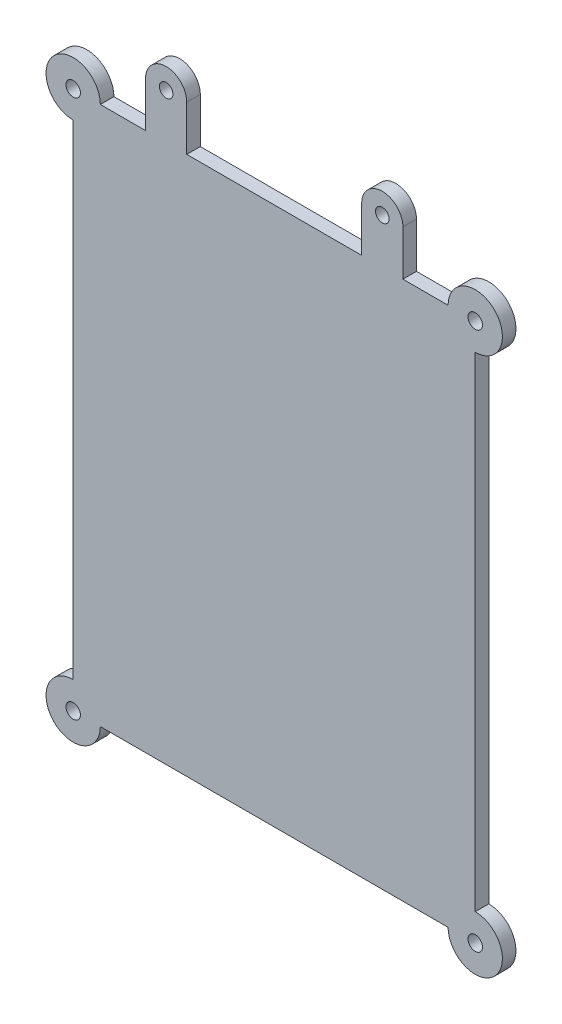
from build123d import *

# Parameters (mm, degrees)
BOSS_EXTRUDE1_DEPTH = 3
SKETCH2_R           = 1.6
CUT_EXTRUDE1_DEPTH  = 10
SKETCH3_R           = 1.5
BOSS_EXTRUDE4_DEPTH = 3


with BuildPart() as part:
    # Sketch1 → Boss-Extrude1 (new body)
    with BuildSketch(Plane.XY):
        with BuildLine():
            Line((38.458853732, -59.570964101), (-38.458853732, -59.570964101))
            ThreePointArc((-38.458853732, -59.570964101), (-48.701494419, -63.813604788), (-44.458853732, -53.570964101))
            Line((-44.458853732, -53.570964101), (-44.458853732, 53.570964101))
            ThreePointArc((-44.458853732, 53.570964101), (-48.701494419, 63.813604788), (-38.458853732, 59.570964101))
            Line((-38.458853732, 59.570964101), (38.458853732, 59.570964101))
            ThreePointArc((38.458853732, 59.570964101), (48.701494419, 63.813604788), (44.458853732, 53.570964101))
            Line((44.458853732, 53.570964101), (44.458853732, -53.570964101))
            ThreePointArc((44.458853732, -53.570964101), (48.701494419, -63.813604788), (38.458853732, -59.570964101))
        make_face()
    extrude(amount=BOSS_EXTRUDE1_DEPTH)

    # Sketch2 → Cut-Extrude1 (cut)
    with BuildSketch(Plane.XY.offset(3)):
        with Locations((-44.458853732, 59.570964101)):
            Circle(SKETCH2_R)
        with Locations((44.458853732, 59.570964101)):
            Circle(SKETCH2_R)
        with Locations((44.458853732, -59.570964101)):
            Circle(SKETCH2_R)
        with Locations((-44.458853732, -59.570964101)):
            Circle(SKETCH2_R)
    extrude(amount=-CUT_EXTRUDE1_DEPTH, mode=Mode.SUBTRACT)

    # Sketch3 → Boss-Extrude4 (add)
    with BuildSketch(Plane.XY.offset(3)):
        with BuildLine():
            Line((19.344784152, 59.570964101), (28.458853732, 59.570964101))
            Line((28.458853732, 59.570964101), (28.458853732, 69.570964101))
            ThreePointArc((28.458853732, 69.570964101), (23.901818942, 74.127998891), (19.344784152, 69.570964101))
            Line((19.344784152, 69.570964101), (19.344784152, 59.570964101))
        make_face()
        with Locations((23.901818942, 69.570964101)):
            Circle(SKETCH3_R, mode=Mode.SUBTRACT)
        with BuildLine():
            Line((-19.344784152, 59.570964101), (-28.458853732, 59.570964101))
            Line((-28.458853732, 59.570964101), (-28.458853732, 69.570964101))
            ThreePointArc((-28.458853732, 69.570964101), (-23.901818942, 74.127998891), (-19.344784152, 69.570964101))
            Line((-19.344784152, 69.570964101), (-19.344784152, 59.570964101))
        make_face()
        with Locations((-23.901818942, 69.570964101)):
            Circle(SKETCH3_R, mode=Mode.SUBTRACT)
    extrude(amount=-BOSS_EXTRUDE4_DEPTH)


solid = part.part
